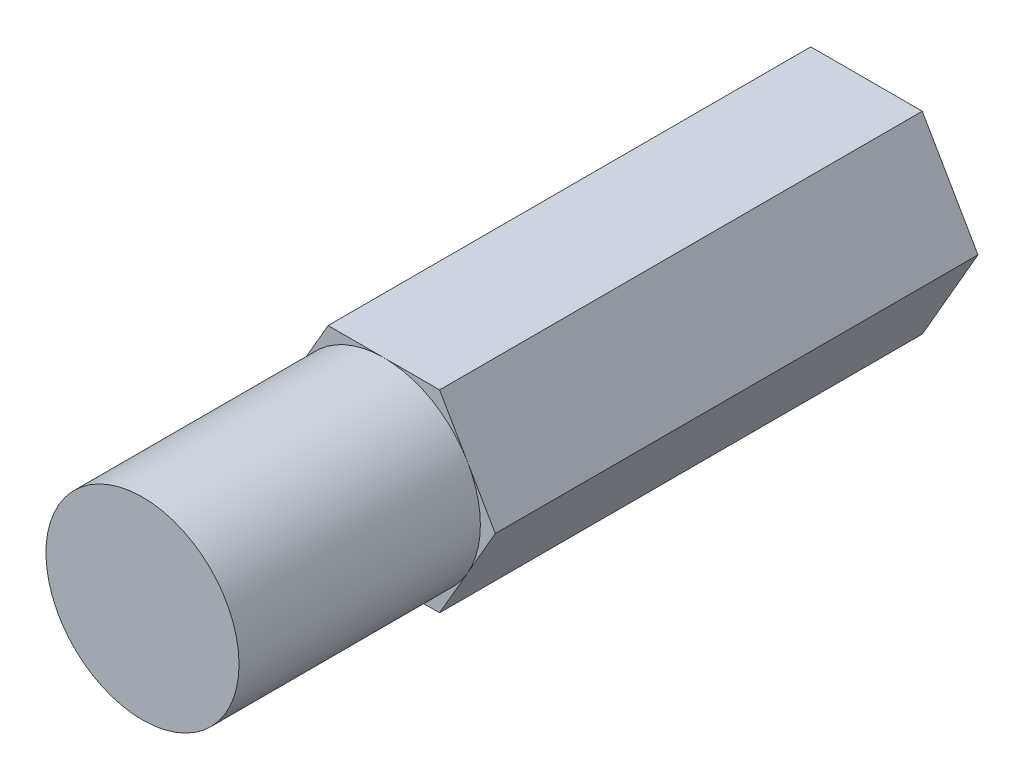
from build123d import *

# Parameters (mm, degrees)
BOSS_EXTRUDE1_DEPTH = 10
SKETCH2_R           = 2
BOSS_EXTRUDE2_DEPTH = 5


with BuildPart() as part:
    # Sketch1 → Boss-Extrude1 (new body)
    with BuildSketch(Plane.XY):
        Polygon((-1.154700538, -2), (1.154700538, -2), (2.309401077, 0), (1.154700538, 2), (-1.154700538, 2), (-2.309401077, 0), align=None)
    extrude(amount=BOSS_EXTRUDE1_DEPTH)

    # Sketch2 → Boss-Extrude2 (add)
    with BuildSketch(Plane.XY.offset(10)):
        Circle(SKETCH2_R)
    extrude(amount=BOSS_EXTRUDE2_DEPTH)


solid = part.part
